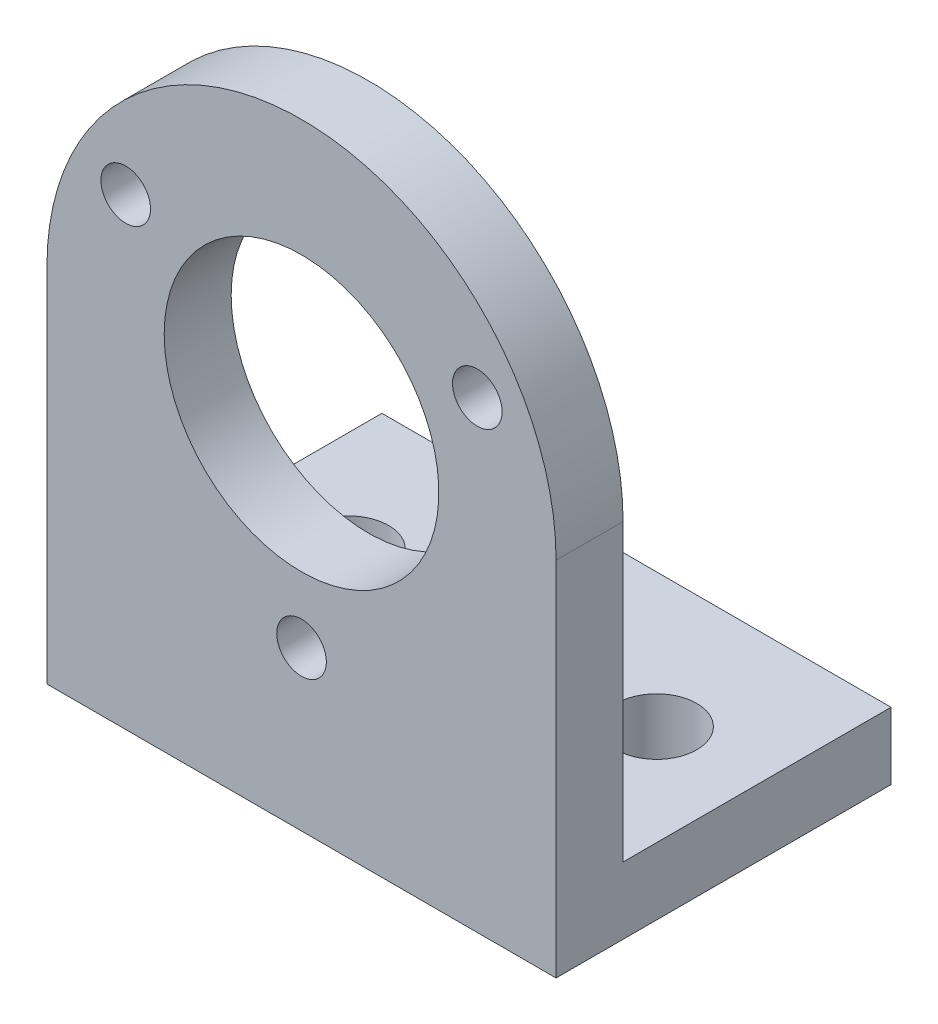
from build123d import *

# Parameters (mm, degrees)
BOSS_EXTRUDE1_DEPTH = 5
SKETCH2_R           = 10.25
SKETCH2_R_2         = 1.85
CUT_EXTRUDE1_DEPTH  = 6
SKETCH3_W           = 38
SKETCH3_H           = 5
BOSS_EXTRUDE2_DEPTH = 20
SKETCH4_R           = 3
CUT_EXTRUDE2_DEPTH  = 6


with BuildPart() as part:
    # Sketch1 → Boss-Extrude1 (new body)
    with BuildSketch(Plane.XY):
        with BuildLine():
            Line((-20.15873891, 0), (-20.15873891, -27))
            Line((-20.15873891, -27), (17.84126109, -27))
            Line((17.84126109, -27), (17.84126109, 0))
            ThreePointArc((17.84126109, 0), (-1.15873891, 19), (-20.15873891, 0))
        make_face()
    extrude(amount=BOSS_EXTRUDE1_DEPTH)

    # Sketch2 → Cut-Extrude1 (cut, through all)
    with BuildSketch(Plane(origin=(0, 0, 0), x_dir=(-1, 0, 0), z_dir=(0, 0, -1))):
        with Locations((1.15873891, 0)):
            Circle(SKETCH2_R)
        with Locations((1.15873891, -15.15)):
            Circle(SKETCH2_R_2)
        with Locations((-11.961545957, 7.575)):
            Circle(SKETCH2_R_2)
        with Locations((14.279023778, 7.575)):
            Circle(SKETCH2_R_2)
    extrude(amount=-CUT_EXTRUDE1_DEPTH, mode=Mode.SUBTRACT)

    # Sketch3 → Boss-Extrude2 (add)
    with BuildSketch(Plane(origin=(0, 0, 0), x_dir=(-1, 0, 0), z_dir=(0, 0, -1))):
        with Locations((1.15873891, -24.5)):
            Rectangle(SKETCH3_W, SKETCH3_H)
    extrude(amount=BOSS_EXTRUDE2_DEPTH)

    # Sketch4 → Cut-Extrude2 (cut, through all)
    with BuildSketch(Plane(origin=(0, -22, 0), x_dir=(1, 0, 0), z_dir=(0, 1, 0))):
        with Locations((10.34126109, 10)):
            Circle(SKETCH4_R)
        with Locations((-12.65873891, 10)):
            Circle(SKETCH4_R)
    extrude(amount=-CUT_EXTRUDE2_DEPTH, mode=Mode.SUBTRACT)


solid = part.part
